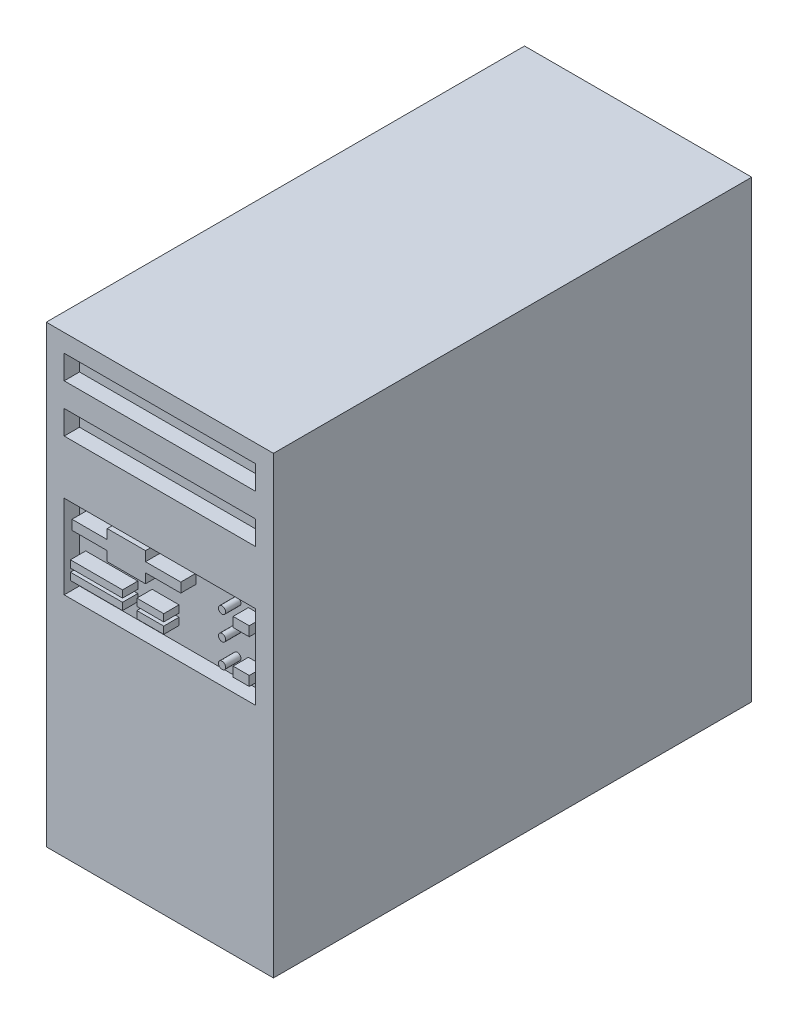
from build123d import *

# Parameters (mm, degrees)
CROQUIS1_W              = 400
CROQUIS1_H              = 380
SALIENTE_EXTRUIR1_DEPTH = 95
CROQUIS2_W              = 30.4
CROQUIS2_H              = 21.7
CROQUIS2_W_2            = 1
CROQUIS2_H_2            = 5
CORTAR_EXTRUIR1_DEPTH   = 14
CROQUIS3_W              = 45
CROQUIS3_H              = 150
CROQUIS3_W_2            = 100
CROQUIS3_H_2            = 15
SALIENTE_EXTRUIR2_DEPTH = 3
CROQUIS4_R              = 6.15
CROQUIS4_R_2            = 4
CROQUIS4_W              = 5
CROQUIS4_H              = 13
CROQUIS4_W_2            = 12
SALIENTE_EXTRUIR3_DEPTH = 5
CROQUIS5_R              = 4.1
CROQUIS5_R_2            = 5.55
SALIENTE_EXTRUIR4_DEPTH = 5
CROQUIS6_W              = 160
CROQUIS6_H              = 70
CROQUIS6_W_2            = 43.6
CROQUIS6_H_2            = 6
CROQUIS6_W_3            = 22.5
CROQUIS6_R              = 3
CROQUIS6_W_4            = 13.5
CROQUIS6_H_3            = 8
CROQUIS6_H_4            = 20
CORTAR_EXTRUIR2_DEPTH   = 12.8


with BuildPart() as part:
    # Croquis1 → Saliente-Extruir1 (new body, symmetric)
    with BuildSketch(Plane(origin=(0, 0, 0), x_dir=(0, 0, -1), z_dir=(1, 0, 0))):
        Rectangle(CROQUIS1_W, CROQUIS1_H)
    extrude(amount=SALIENTE_EXTRUIR1_DEPTH, both=True)

    # Croquis2 → Cortar-Extruir1 (cut)
    with BuildSketch(Plane(origin=(0, 0, -200), x_dir=(-1, 0, 0), z_dir=(0, 0, -1))):
        with Locations((-55, 160)):
            Rectangle(CROQUIS2_W, CROQUIS2_H)
        Polygon((-42, 151), (-68, 151), (-68, 160), (-68, 164.669872981), (-62.5, 169), (-47.5, 169), (-42, 164.669872981), (-42, 160), align=None, mode=Mode.SUBTRACT)
        with Locations((-55, 162.856907895)):
            Rectangle(CROQUIS2_W_2, CROQUIS2_H_2)
        with Locations((-48.5, 155)):
            Rectangle(CROQUIS2_W_2, CROQUIS2_H_2)
        with Locations((-61.5, 155)):
            Rectangle(CROQUIS2_W_2, CROQUIS2_H_2)
        Polygon((-85, 90), (-25, 90), (-25, -70), (30, -70), (30, -165), (-85, -165), align=None)
    extrude(amount=-CORTAR_EXTRUIR1_DEPTH, mode=Mode.SUBTRACT)

    # Croquis3 → Saliente-Extruir2 (add)
    with BuildSketch(Plane(origin=(0, 0, -186), x_dir=(-1, 0, 0), z_dir=(0, 0, -1))):
        with Locations((-58, 12.5)):
            Rectangle(CROQUIS3_W, CROQUIS3_H)
        with Locations((-22.5, -85)):
            Rectangle(CROQUIS3_W_2, CROQUIS3_H_2)
    extrude(amount=SALIENTE_EXTRUIR2_DEPTH)

    # Croquis4 → Saliente-Extruir3 (add)
    with BuildSketch(Plane(origin=(0, 0, -189), x_dir=(-1, 0, 0), z_dir=(0, 0, -1))):
        with Locations((-69, 76)):
            Circle(CROQUIS4_R)
        with Locations((-50, 76)):
            Circle(CROQUIS4_R)
        with Locations((-68, -57.5)):
            Circle(CROQUIS4_R_2)
        with Locations((-56, -57.5)):
            Circle(CROQUIS4_R_2)
        with Locations((-43, -57.5)):
            Circle(CROQUIS4_R_2)
        with BuildLine():
            Line((-65.269265107, 53.441675937), (-70.469265107, 52.735154197))
            ThreePointArc((-70.469265107, 52.735154197), (-71.706408015, 52.068936991), (-72.2, 50.753363012))
            Line((-72.2, 50.753363012), (-72.2, 41.246636988))
            ThreePointArc((-72.2, 41.246636988), (-71.706408015, 39.931063009), (-70.469265107, 39.264845803))
            Line((-70.469265107, 39.264845803), (-65.269265107, 38.558324063))
            ThreePointArc((-65.269265107, 38.558324063), (-63.684426021, 39.033707234), (-63, 40.540115249))
            Line((-63, 40.540115249), (-63, 51.459884751))
            ThreePointArc((-63, 51.459884751), (-63.684426021, 52.966292766), (-65.269265107, 53.441675937))
        make_face()
        with BuildLine():
            Line((-52.36857707, 53.105891799), (-48.36857707, 53.855891799))
            ThreePointArc((-48.36857707, 53.855891799), (-46.722728326, 53.429165642), (-46, 51.890147425))
            Line((-46, 51.890147425), (-46, 16.709852575))
            ThreePointArc((-46, 16.709852575), (-46.722728326, 15.170834358), (-48.36857707, 14.744108201))
            Line((-48.36857707, 14.744108201), (-52.36857707, 15.494108201))
            ThreePointArc((-52.36857707, 15.494108201), (-53.539018216, 16.1825809), (-54, 17.459852575))
            Line((-54, 17.459852575), (-54, 51.140147425))
            ThreePointArc((-54, 51.140147425), (-53.539018216, 52.4174191), (-52.36857707, 53.105891799))
        make_face()
        with BuildLine():
            Line((-68.25, 23), (-70, 23))
            Line((-70, 23), (-70, 4))
            Line((-70, 4), (-68.25, 4))
            ThreePointArc((-68.25, 4), (-65, 0.75), (-61.75, 4))
            Line((-61.75, 4), (-60, 4))
            Line((-60, 4), (-60, 23))
            Line((-60, 23), (-61.75, 23))
            ThreePointArc((-61.75, 23), (-65, 26.25), (-68.25, 23))
        make_face()
        with Locations((-63, -13.5)):
            Rectangle(CROQUIS4_W, CROQUIS4_H)
        with Locations((-71, -13.5)):
            Rectangle(CROQUIS4_W, CROQUIS4_H)
        with Locations((-63, -40.5)):
            Rectangle(CROQUIS4_W, CROQUIS4_H)
        with Locations((-71, -40.5)):
            Rectangle(CROQUIS4_W, CROQUIS4_H)
        with BuildLine():
            Line((-46, -20.5), (-46, -6.5))
            Line((-46, -6.5), (-56, -6.5))
            Line((-56, -6.5), (-56, -20.5))
            ThreePointArc((-56, -20.5), (-51, -25.5), (-46, -20.5))
        make_face()
        with Locations((-50, -40.5)):
            Rectangle(CROQUIS4_W_2, CROQUIS4_H)
    extrude(amount=SALIENTE_EXTRUIR3_DEPTH)

    # Croquis5 → Saliente-Extruir4 (add)
    with BuildSketch(Plane(origin=(0, 0, -189), x_dir=(-1, 0, 0), z_dir=(0, 0, -1))):
        with Locations((-13, -85)):
            Circle(CROQUIS5_R)
        with Locations((-28, -85)):
            Circle(CROQUIS5_R_2)
        with BuildLine():
            Line((-54.378732187, -82.51492875), (-55.378732187, -86.51492875))
            ThreePointArc((-55.378732187, -86.51492875), (-55.014858063, -88.230824419), (-53.438447187, -89))
            Line((-53.438447187, -89), (-42.561552813, -89))
            ThreePointArc((-42.561552813, -89), (-40.985141937, -88.230824419), (-40.621267813, -86.51492875))
            Line((-40.621267813, -86.51492875), (-41.621267813, -82.51492875))
            ThreePointArc((-41.621267813, -82.51492875), (-42.330728394, -81.423589124), (-43.561552813, -81))
            Line((-43.561552813, -81), (-52.438447187, -81))
            ThreePointArc((-52.438447187, -81), (-53.669271606, -81.423589124), (-54.378732187, -82.51492875))
        make_face()
    extrude(amount=SALIENTE_EXTRUIR4_DEPTH)

    # Croquis6 → Cortar-Extruir2 (cut)
    with BuildSketch(Plane.XY.offset(200)):
        with Locations((0, 35)):
            Rectangle(CROQUIS6_W, CROQUIS6_H)
        with Locations((-53, 16)):
            Rectangle(CROQUIS6_W_2, CROQUIS6_H_2, mode=Mode.SUBTRACT)
        with Locations((-53, 25)):
            Rectangle(CROQUIS6_W_2, CROQUIS6_H_2, mode=Mode.SUBTRACT)
        with Locations((-8, 16)):
            Rectangle(CROQUIS6_W_3, CROQUIS6_H_2, mode=Mode.SUBTRACT)
        with Locations((-8, 25)):
            Rectangle(CROQUIS6_W_3, CROQUIS6_H_2, mode=Mode.SUBTRACT)
        Polygon((17.5, 58), (17.5, 50), (-12, 50), (-12, 42), (-44, 42), (-44, 50), (-73.5, 50), (-73.5, 58), (-44, 58), (-44, 66), (-12, 66), (-12, 58), align=None, mode=Mode.SUBTRACT)
        with Locations((52, 15)):
            Circle(CROQUIS6_R, mode=Mode.SUBTRACT)
        with Locations((68, 15)):
            Rectangle(CROQUIS6_W_4, CROQUIS6_H_3, mode=Mode.SUBTRACT)
        with Locations((52, 35)):
            Circle(CROQUIS6_R, mode=Mode.SUBTRACT)
        with Locations((52, 55)):
            Circle(CROQUIS6_R, mode=Mode.SUBTRACT)
        with Locations((68, 51)):
            Rectangle(CROQUIS6_W_4, CROQUIS6_H_3, mode=Mode.SUBTRACT)
        with Locations((0, 165)):
            Rectangle(CROQUIS6_W, CROQUIS6_H_4)
        with Locations((0, 125)):
            Rectangle(CROQUIS6_W, CROQUIS6_H_4)
    extrude(amount=-CORTAR_EXTRUIR2_DEPTH, mode=Mode.SUBTRACT)


solid = part.part
